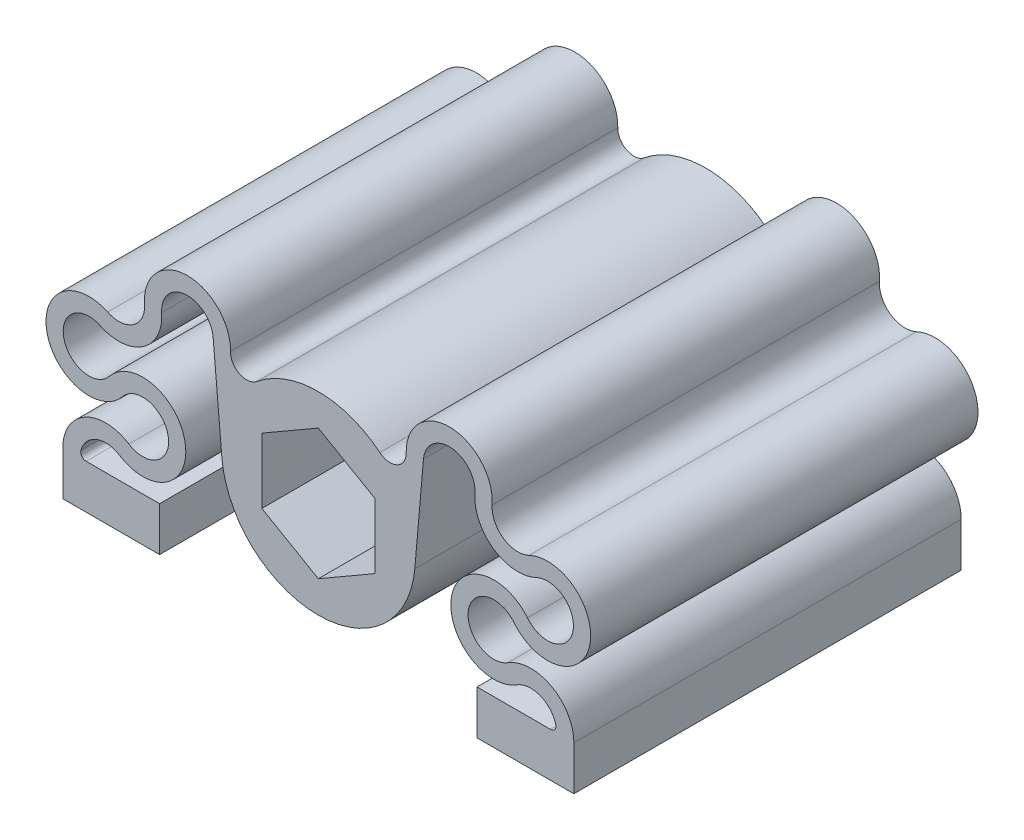
from build123d import *

# Parameters (mm, degrees)
SKETCH1_R           = 3.25
BOSS_EXTRUDE1_DEPTH = 36
SKETCH2_R           = 2.6
CUT_EXTRUDE1_DEPTH  = 4.2
CUT_EXTRUDE3_DEPTH  = 7
CUT_EXTRUDE2_DEPTH  = 24
SKETCH6_R           = 3.25
BOSS_EXTRUDE2_DEPTH = 0.4
CHAMFER1_SIZE       = 1


with BuildPart() as part:
    # Sketch1 → Boss-Extrude1 (new body)
    with BuildSketch(Plane.XY):
        with BuildLine():
            Line((-14.75, -7.4), (-14.75, -11.5))
            Line((-14.75, -11.5), (-23.75, -11.5))
            Line((-23.75, -11.5), (-23.75, -7.4))
            ThreePointArc((-23.75, -7.4), (-21.675125708, -3.893735462), (-17.603054495, -4.025))
            ThreePointArc((-17.603054495, -4.025), (-13.947306078, -1.606859229), (-18.188386592, -0.5))
            ThreePointArc((-18.188386592, -0.5), (-25.210418213, 1.109132257), (-19.583771133, 5.607918465))
            ThreePointArc((-19.583771133, 5.607918465), (-17.193366172, 5.79117644), (-16.154186894, 7.951668465))
            ThreePointArc((-16.154186894, 7.951668465), (-12.264338175, 12.248774426), (-8.166591783, 8.149443113))
            ThreePointArc((-8.166591783, 8.149443113), (-7.324900269, 6.763678693), (-5.714627865, 6.952915098))
            ThreePointArc((-5.714627865, 6.952915098), (0, 9), (5.714627865, 6.952915098))
            ThreePointArc((5.714627865, 6.952915098), (7.324900269, 6.763678693), (8.166591783, 8.149443113))
            ThreePointArc((8.166591783, 8.149443113), (12.264338175, 12.248774426), (16.154186894, 7.951668465))
            ThreePointArc((16.154186894, 7.951668465), (17.193366172, 5.79117644), (19.583771133, 5.607918465))
            ThreePointArc((19.583771133, 5.607918465), (25.210418213, 1.109132257), (18.188386592, -0.5))
            ThreePointArc((18.188386592, -0.5), (13.947306078, -1.606859229), (17.603054495, -4.025))
            ThreePointArc((17.603054495, -4.025), (21.675125708, -3.893735462), (23.75, -7.4))
            Line((23.75, -7.4), (23.75, -11.5))
            Line((23.75, -11.5), (14.75, -11.5))
            Line((14.75, -11.5), (14.75, -7.4))
            Line((14.75, -7.4), (21.583030278, -7.4))
            ThreePointArc((21.583030278, -7.4), (21.980389985, -7.203488489), (22.065406667, -6.768421053))
            ThreePointArc((22.065406667, -6.768421053), (20.615569602, -5.16152077), (18.461832697, -5.375))
            ThreePointArc((18.461832697, -5.375), (12.368918668, -1.344765382), (19.437386192, 0.5))
            ThreePointArc((19.437386192, 0.5), (23.650605164, 1.465479354), (20.274616916, 4.164751079))
            ThreePointArc((20.274616916, 4.164751079), (16.290608649, 4.470181037), (14.558643186, 8.071001079))
            ThreePointArc((14.558643186, 8.071001079), (12.359417834, 10.642138999), (9.774460347, 8.459173783))
            Line((9.774460347, 8.459173783), (8.965752283, -0.784401685))
            ThreePointArc((8.965752283, -0.784401685), (0, -9), (-8.965752283, -0.784401685))
            Line((-8.965752283, -0.784401685), (-9.774460347, 8.459173783))
            ThreePointArc((-9.774460347, 8.459173783), (-12.359417834, 10.642138999), (-14.558643186, 8.071001079))
            ThreePointArc((-14.558643186, 8.071001079), (-16.290608649, 4.470181037), (-20.274616916, 4.164751079))
            ThreePointArc((-20.274616916, 4.164751079), (-23.650605164, 1.465479354), (-19.437386192, 0.5))
            ThreePointArc((-19.437386192, 0.5), (-12.368918668, -1.344765382), (-18.461832697, -5.375))
            ThreePointArc((-18.461832697, -5.375), (-20.615569602, -5.16152077), (-22.065406667, -6.768421053))
            ThreePointArc((-22.065406667, -6.768421053), (-21.980389985, -7.203488489), (-21.583030278, -7.4))
            Line((-21.583030278, -7.4), (-14.75, -7.4))
        make_face()
        Circle(SKETCH1_R, mode=Mode.SUBTRACT)
    extrude(amount=BOSS_EXTRUDE1_DEPTH)

    # Sketch2 → Cut-Extrude1 (cut)
    with BuildSketch(Plane.XZ.offset(11.5)):
        with Locations(Location((-19.225, 30.5, 0), (0, 0, 270))):  # turned: the seam where the file's is
            Circle(SKETCH2_R)
        with Locations(Location((-19.225, 5.5, 0), (0, 0, 270))):  # turned: the seam where the file's is
            Circle(SKETCH2_R)
        with Locations(Location((19.225, 5.5, 0), (0, 0, 270))):  # turned: the seam where the file's is
            Circle(SKETCH2_R)
        with Locations(Location((19.225, 30.5, 0), (0, 0, 270))):  # turned: the seam where the file's is
            Circle(SKETCH2_R)
    extrude(amount=-CUT_EXTRUDE1_DEPTH, mode=Mode.SUBTRACT)

    # Sketch5 → Cut-Extrude3 (cut)
    with BuildSketch(Plane.XY):
        Polygon((5.25, -3.031088913), (5.25, 3.031088913), (0, 6.062177826), (-5.25, 3.031088913), (-5.25, -3.031088913), (0, -6.062177826), align=None)
    extrude(amount=CUT_EXTRUDE3_DEPTH, mode=Mode.SUBTRACT)

    # Sketch3 → Cut-Extrude2 (cut)
    with BuildSketch(Plane.XY.offset(36)):
        Polygon((5.25, -3.031088913), (5.25, 3.031088913), (0, 6.062177826), (-5.25, 3.031088913), (-5.25, -3.031088913), (0, -6.062177826), align=None)
    extrude(amount=-CUT_EXTRUDE2_DEPTH, mode=Mode.SUBTRACT)

    # Sketch6 → Boss-Extrude2 (add)
    with BuildSketch(Plane(origin=(0, 0, 7), x_dir=(-1, 0, 0), z_dir=(0, 0, -1))):
        Circle(SKETCH6_R)
    extrude(amount=-BOSS_EXTRUDE2_DEPTH)

    # Chamfer1
    chamfer1_edges = [part.edges().sort_by_distance(p)[0] for p in [
        (2.625, -4.54663337, 0),
        (5.25, 0, 0),
        (2.625, 4.54663337, 0),
        (-2.625, 4.54663337, 0),
        (-5.25, 0, 0),
        (-2.625, -4.54663337, 0),
    ]]
    chamfer(chamfer1_edges, length=CHAMFER1_SIZE)


solid = part.part
